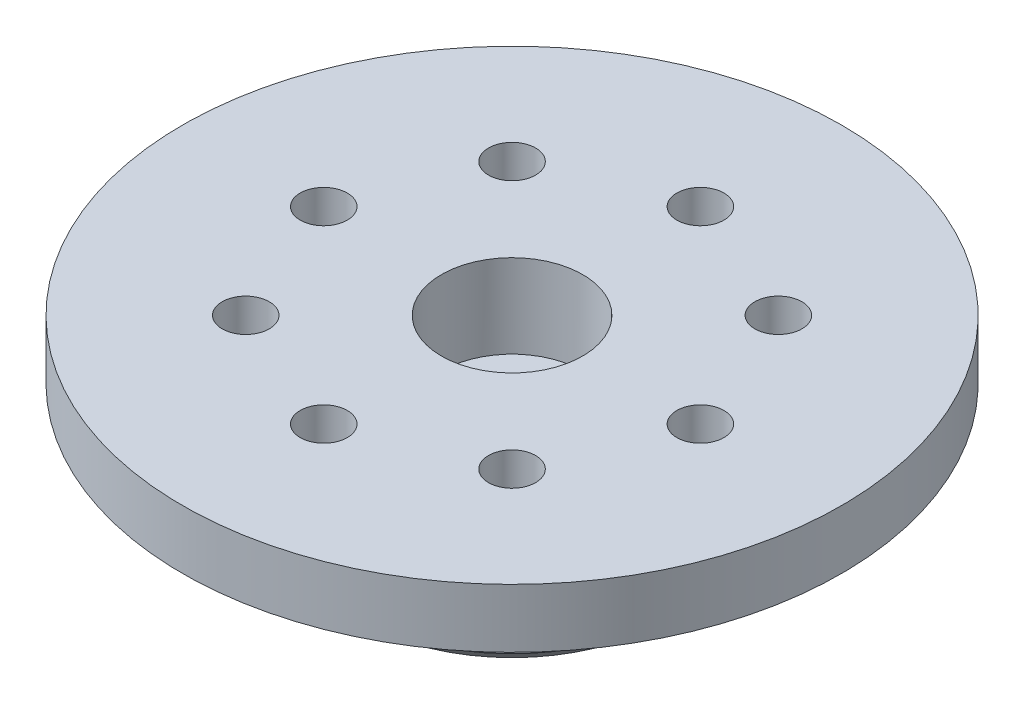
from build123d import *

# Parameters (mm, degrees)
IZIM1_W                     = 14
IZIM1_H                     = 2.5
IZIM7_R                     = 5.5
KES_EKSTR_ZYON1_DEPTH       = 12.55
IZIM9_R                     = 5.5
IZIM9_R_2                   = 3
Y_KSEKLIK_EKSTR_ZYON2_DEPTH = 5.55
IZIM11_R                    = 3
IZIM11_R_2                  = 1
Y_KSEKLIK_EKSTR_ZYON3_DEPTH = 2
IZIM12_R                    = 1
KES_EKSTR_ZYON2_DEPTH       = 10
IZIM16_R                    = 7
IZIM16_R_2                  = 5.5
Y_KSEKLIK_EKSTR_ZYON4_DEPTH = 5.5
PAH1_SIZE                   = 0.5
IZIM17_R                    = 7
IZIM17_R_2                  = 5.8
KES_EKSTR_ZYON3_DEPTH       = 2
PAH2_SIZE                   = 1


with BuildPart() as part:
    # Çizim1 → Döndür1 (revolve)
    with BuildSketch(Plane.XY):
        with Locations((7, -1.25)):
            Rectangle(IZIM1_W, IZIM1_H)
    revolve(axis=Axis((0, 0, 0), (0, -1, 0)))

    # Çizim7 → Kes-Ekstrüzyon1 (cut)
    with BuildSketch(Plane.XZ.offset(2.5)):
        Circle(IZIM7_R)
    extrude(amount=-KES_EKSTR_ZYON1_DEPTH, mode=Mode.SUBTRACT)

    # Çizim9 → Yükseklik-Ekstrüzyon2 (add)
    with BuildSketch(Plane(origin=(0, 0, 0), x_dir=(1, 0, 0), z_dir=(0, 1, 0))):
        Circle(IZIM9_R)
        Circle(IZIM9_R_2, mode=Mode.SUBTRACT)
    extrude(amount=-Y_KSEKLIK_EKSTR_ZYON2_DEPTH)

    # Çizim11 → Yükseklik-Ekstrüzyon3 (add)
    with BuildSketch(Plane.XZ.offset(5.55)):
        Circle(IZIM11_R)
        Circle(IZIM11_R_2, mode=Mode.SUBTRACT)
    extrude(amount=-Y_KSEKLIK_EKSTR_ZYON3_DEPTH)

    # Çizim12 → Kes-Ekstrüzyon2 (cut)
    with BuildSketch(Plane(origin=(0, 0, 0), x_dir=(1, 0, 0), z_dir=(0, 1, 0))):
        with Locations((0, 8)):
            Circle(IZIM12_R)
        with Locations((5.656854249, 5.656854249)):
            Circle(IZIM12_R)
        with Locations((8, 0)):
            Circle(IZIM12_R)
        with Locations((5.656854249, -5.656854249)):
            Circle(IZIM12_R)
        with Locations((0, -8)):
            Circle(IZIM12_R)
        with Locations((-5.656854249, -5.656854249)):
            Circle(IZIM12_R)
        with Locations((-8, 0)):
            Circle(IZIM12_R)
        with Locations((-5.656854249, 5.656854249)):
            Circle(IZIM12_R)
    extrude(amount=-KES_EKSTR_ZYON2_DEPTH, mode=Mode.SUBTRACT)

    # Çizim16 → Yükseklik-Ekstrüzyon4 (add)
    with BuildSketch(Plane.XZ.offset(2.5)):
        Circle(IZIM16_R)
        Circle(IZIM16_R_2, mode=Mode.SUBTRACT)
    extrude(amount=Y_KSEKLIK_EKSTR_ZYON4_DEPTH)

    # Pah1
    pah1_edges = [part.edges().sort_by_distance(p)[0] for p in [
        (-7, -8, 0),
    ]]
    chamfer(pah1_edges, length=PAH1_SIZE)

    # Çizim17 → Kes-Ekstrüzyon3 (cut)
    with BuildSketch(Plane.XZ.offset(2.5)):
        Circle(IZIM17_R)
        Circle(IZIM17_R_2, mode=Mode.SUBTRACT)
    extrude(amount=KES_EKSTR_ZYON3_DEPTH, mode=Mode.SUBTRACT)

    # Pah2
    pah2_edges = [part.edges().sort_by_distance(p)[0] for p in [
        (-5.8, -4.5, 0),
    ]]
    chamfer(pah2_edges, length=PAH2_SIZE)


solid = part.part
